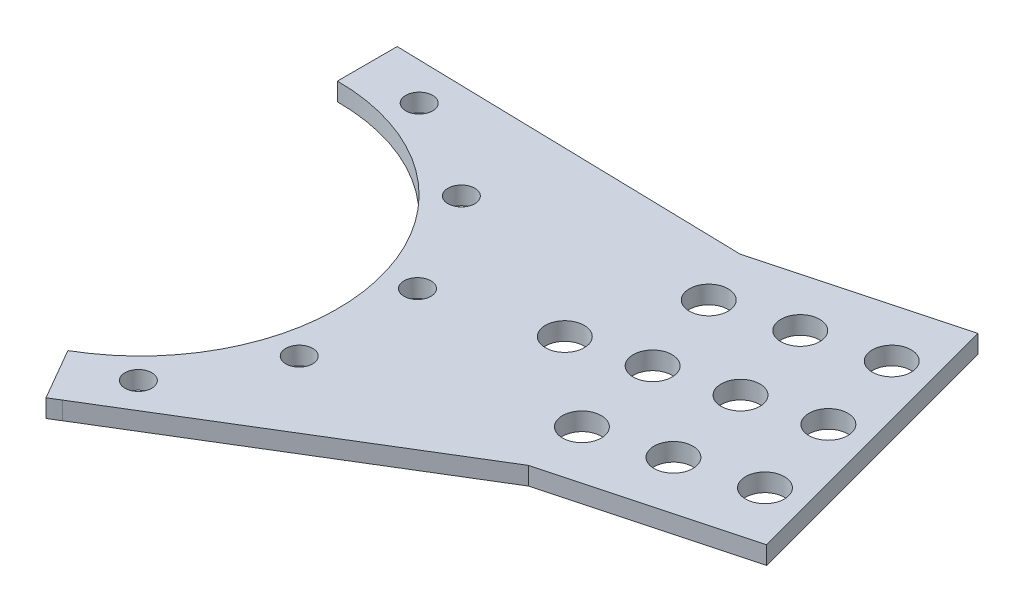
from build123d import *

# Parameters (mm, degrees)
BOSS_EXTRUDE1_DEPTH             = 1.5
BOSS_EXTRUDE2_DEPTH             = 1.5
BOSS_EXTRUDE3_DEPTH             = 1.5
CUT_EXTRUDE1_START              = -4
SKETCH2_R                       = 2.25
CUT_EXTRUDE1_DEPTH              = 5
CIRPATTERN1_COUNT               = 3
CIRPATTERN1_ANGLE               = 60
CIRPATTERN1_THE_OTHER_WAY_COUNT = 3
CIRPATTERN1_THE_OTHER_WAY_ANGLE = 60
CUT_EXTRUDE2_START              = -4
SKETCH6_R                       = 3.25
CUT_EXTRUDE2_DEPTH              = 5
LPATTERN1_COUNT                 = 3
LPATTERN1_PITCH                 = 12.5
SKETCH7_R                       = 3.25
CUT_EXTRUDE3_DEPTH              = 10
LPATTERN2_COUNT                 = 4
LPATTERN2_PITCH                 = 12


with BuildPart() as part:
    # Sketch1 → Boss-Extrude1 (new body, symmetric)
    with BuildSketch(Plane(origin=(0, 0, 0), x_dir=(1, 0, 0), z_dir=(0, 1, 0))):
        with BuildLine():
            Line((0, 33), (0, 43))
            ThreePointArc((0, 43), (41.53481053, 11.129218939), (21.5, -37.239092363))
            Line((21.5, -37.239092363), (16.5, -28.578838325))
            ThreePointArc((16.5, -28.578838325), (31.875552268, 8.541028488), (0, 33))
        make_face()
    extrude(amount=BOSS_EXTRUDE1_DEPTH, both=True)

    # Sketch4 → Boss-Extrude2 (add, symmetric)
    with BuildSketch(Plane(origin=(0, 0, 0), x_dir=(1, 0, 0), z_dir=(0, 1, 0))):
        Polygon((90.122106501, 50.030050167), (25.40507614, 32.689174146), (38.346028395, -15.607117169), (103.063058756, 1.733758853), align=None)
    extrude(amount=BOSS_EXTRUDE2_DEPTH, both=True)

    # Sketch5 → Boss-Extrude3 (add, symmetric)
    with BuildSketch(Plane(origin=(0, 0, 0), x_dir=(1, 0, 0), z_dir=(0, 1, 0))):
        Polygon((0, 43), (58.722616268, 41.616582117), (27.323126035, 33.203114066), align=None)
        Polygon((71.663568523, -6.679709198), (40.26407829, -15.093177248), (21.5, -37.239092363), align=None)
    extrude(amount=BOSS_EXTRUDE3_DEPTH, both=True)

    # Sketch2 → Cut-Extrude1 (cut)
    with BuildSketch(Plane(origin=(0, 1.5, 0), x_dir=(1, 0, 0), z_dir=(0, 1, 0)).offset(CUT_EXTRUDE1_START)):
        with Locations((36.757261811, 9.638656763)):
            Circle(SKETCH2_R)
    cut_extrude1 = extrude(amount=CUT_EXTRUDE1_DEPTH, mode=Mode.SUBTRACT)

    # CirPattern1: Cut-Extrude1 ×3 about axis
    cirpattern1_axis = Axis((0, 0, 0), (0, -1, 0))
    for i in range(1, CIRPATTERN1_COUNT):
        add(cut_extrude1.rotate(cirpattern1_axis, i * CIRPATTERN1_ANGLE / (CIRPATTERN1_COUNT - 1)), mode=Mode.SUBTRACT)

    # CirPattern1 the other way: Cut-Extrude1 ×3 about axis
    cirpattern1_the_other_way_axis = Axis((0, 0, 0), (0, 1, 0))
    for i in range(1, CIRPATTERN1_THE_OTHER_WAY_COUNT):
        add(cut_extrude1.rotate(cirpattern1_the_other_way_axis, i * CIRPATTERN1_THE_OTHER_WAY_ANGLE / (CIRPATTERN1_THE_OTHER_WAY_COUNT - 1)), mode=Mode.SUBTRACT)

    # Sketch6 → Cut-Extrude2 (cut)
    with BuildSketch(Plane(origin=(0, 1.5, 0), x_dir=(1, 0, 0), z_dir=(0, 1, 0)).offset(CUT_EXTRUDE2_START)):
        with Locations((94.679313348, 9.840102845)):
            Circle(SKETCH6_R)
        with Locations((86.914741995, 38.817877634)):
            Circle(SKETCH6_R)
    cut_extrude2 = extrude(amount=CUT_EXTRUDE2_DEPTH, mode=Mode.SUBTRACT)

    # LPattern1: Cut-Extrude2 ×3
    with Locations(*[Vector(-0.965925826, 0, 0.258819045) * (i * LPATTERN1_PITCH) for i in range(1, LPATTERN1_COUNT)]):
        add(cut_extrude2, mode=Mode.SUBTRACT)

    # Sketch7 → Cut-Extrude3 (cut)
    with BuildSketch(Plane(origin=(0, 1.5, 0), x_dir=(1, 0, 0), z_dir=(0, 1, 0))):
        with Locations((90.797027671, 24.32899024)):
            Circle(SKETCH7_R)
    cut_extrude3 = extrude(amount=-CUT_EXTRUDE3_DEPTH, mode=Mode.SUBTRACT)

    # LPattern2: Cut-Extrude3 ×4
    with Locations(*[Vector(-0.965925826, 0, 0.258819045) * (i * LPATTERN2_PITCH) for i in range(1, LPATTERN2_COUNT)]):
        add(cut_extrude3, mode=Mode.SUBTRACT)


solid = part.part
